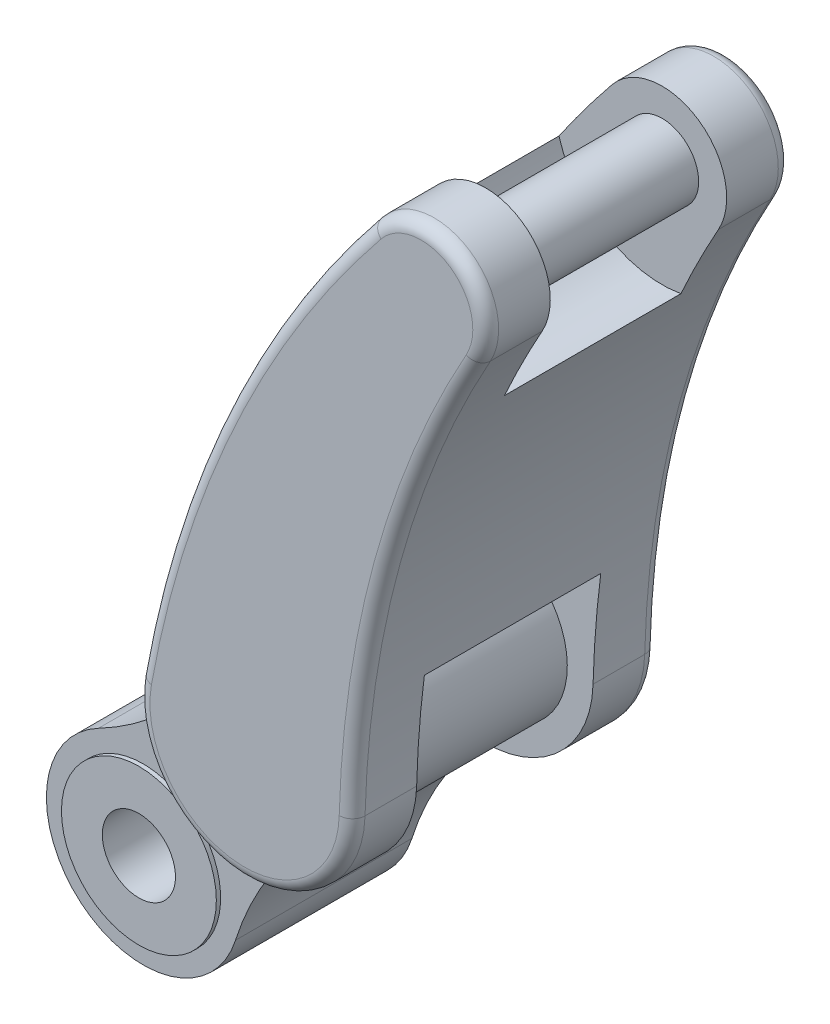
from build123d import *

# Parameters (mm, degrees)
SKETCH1_R           = 42.5
BOSS_EXTRUDE1_DEPTH = 102.5
SKETCH2_R           = 90
SKETCH2_R_2         = 42.5
BOSS_EXTRUDE2_DEPTH = 5
SKETCH3_R           = 90
SKETCH3_R_2         = 42.5
BOSS_EXTRUDE3_DEPTH = 5
BOSS_EXTRUDE4_DEPTH = 75
BOSS_EXTRUDE5_DEPTH = 75
FILLET2_R           = 15
SKETCH6_R           = 42.5
BOSS_EXTRUDE6_DEPTH = 205


with BuildPart() as part:
    # Sketch1 → Boss-Extrude1 (new body, symmetric)
    with BuildSketch(Plane.XY):
        with BuildLine():
            ThreePointArc((-52.068634079, 99.725159038), (-72.31360609, -86.179999851), (107.251733212, -33.960502395))
            ThreePointArc((107.251733212, -33.960502395), (160.82695798, 70.255427056), (245.798784868, 150.946525051))
            ThreePointArc((245.798784868, 150.946525051), (253.901105826, 302.587555032), (105.970797095, 268.276138019))
            ThreePointArc((105.970797095, 268.276138019), (41.260781083, 170.583361992), (-52.068634079, 99.725159038))
        make_face()
        Circle(SKETCH1_R, mode=Mode.SUBTRACT)
    extrude(amount=BOSS_EXTRUDE1_DEPTH, both=True)

    # Sketch2 → Boss-Extrude2 (add)
    with BuildSketch(Plane.XY.offset(102.5)):
        Circle(SKETCH2_R)
        Circle(SKETCH2_R_2, mode=Mode.SUBTRACT)
    extrude(amount=BOSS_EXTRUDE2_DEPTH)

    # Sketch3 → Boss-Extrude3 (add)
    with BuildSketch(Plane(origin=(0, 0, -102.5), x_dir=(-1, 0, 0), z_dir=(0, 0, -1))):
        Circle(SKETCH3_R)
        Circle(SKETCH3_R_2, mode=Mode.SUBTRACT)
    extrude(amount=BOSS_EXTRUDE3_DEPTH)

    # Sketch4 → Boss-Extrude4 (add)
    with BuildSketch(Plane.XY.offset(102.5)):
        with BuildLine():
            ThreePointArc((339.810505034, 840.887250831), (167.534603821, 563.507294819), (69.811758527, 251.948517629))
            ThreePointArc((69.811758527, 251.948517629), (180.075530777, 105.466386029), (317.792368114, 226.500212138))
            ThreePointArc((317.792368114, 226.500212138), (358.459856731, 500.613644392), (463.518163787, 757.040574513))
            ThreePointArc((463.518163787, 757.040574513), (440.127359965, 855.712385585), (339.810505034, 840.887250831))
        make_face()
    extrude(amount=BOSS_EXTRUDE4_DEPTH)

    # Sketch5 → Boss-Extrude5 (add)
    with BuildSketch(Plane(origin=(0, 0, -102.5), x_dir=(-1, 0, 0), z_dir=(0, 0, -1))):
        with BuildLine():
            ThreePointArc((-317.792368114, 226.500212138), (-180.075530777, 105.466386029), (-69.811758527, 251.948517629))
            ThreePointArc((-69.811758527, 251.948517629), (-167.534603821, 563.507294819), (-339.810505034, 840.887250831))
            ThreePointArc((-339.810505034, 840.887250831), (-440.127359965, 855.712385585), (-463.518163787, 757.040574513))
            ThreePointArc((-463.518163787, 757.040574513), (-358.459856731, 500.613644392), (-317.792368114, 226.500212138))
        make_face()
    extrude(amount=BOSS_EXTRUDE5_DEPTH)

    # Fillet2
    fillet2_edges = [part.edges().sort_by_distance(p)[0] for p in [
        (167.534603821, 563.507294819, 177.5),
        (180.075530777, 105.466386029, 177.5),
        (358.459856731, 500.613644392, 177.5),
        (440.127359965, 855.712385585, 177.5),
        (358.459856731, 500.613644392, -177.5),
        (180.075530777, 105.466386029, -177.5),
        (167.534603821, 563.507294819, -177.5),
        (440.127359965, 855.712385585, -177.5),
    ]]
    fillet(fillet2_edges, radius=FILLET2_R)

    # Sketch6 → Boss-Extrude6 (add)
    with BuildSketch(Plane.XY.offset(-102.5)):
        with Locations((398.048368901, 793.628905407)):
            Circle(SKETCH6_R)
        with BuildLine():
            ThreePointArc((419.855651368, 670.545834145), (361.07481022, 509.978649739), (326.751661219, 342.470651611))
            ThreePointArc((326.751661219, 342.470651611), (219.389147641, 402.787161518), (98.878270441, 377.451037787))
            ThreePointArc((98.878270441, 377.451037787), (172.976016961, 575.222465787), (278.119497696, 758.385950771))
            ThreePointArc((278.119497696, 758.385950771), (332.200566612, 687.378884543), (419.855651368, 670.545834145))
        make_face()
    extrude(amount=BOSS_EXTRUDE6_DEPTH)


solid = part.part
